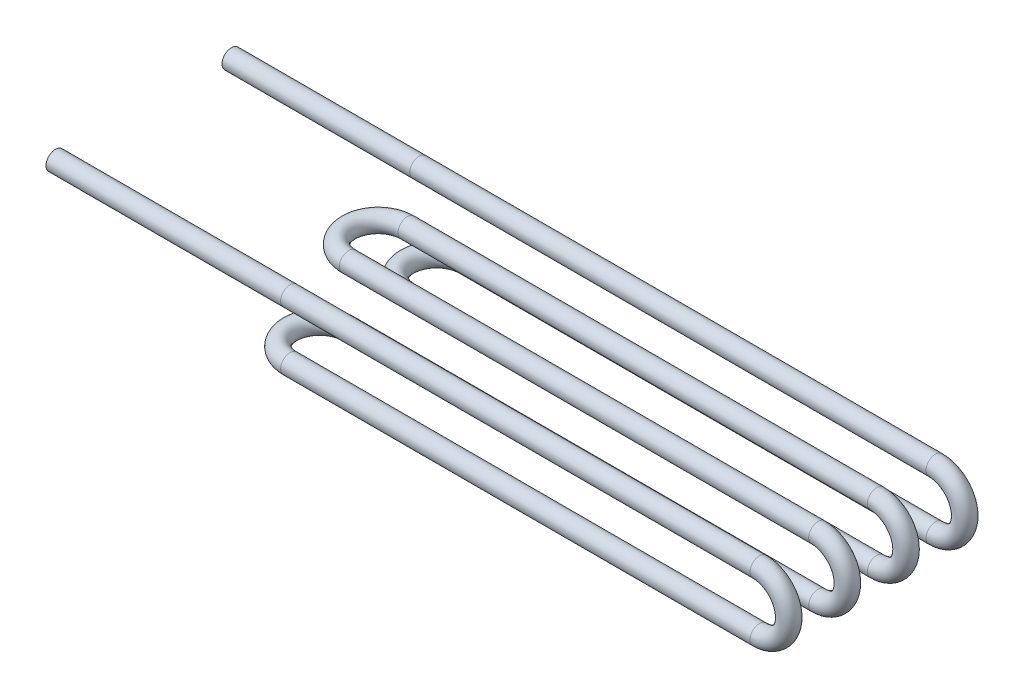
from build123d import *

# Parameters (mm, degrees)
SKETCH2_R   = 4
SKETCH2_R_2 = 3


with BuildPart() as part:
    # Sweep1: sweep along a curve in space
    with BuildLine() as sweep1_path:
        Line((20, 0, 74.999233924), (-80, 0, 74.999233924))
        Line((220, 0, 74.999233924), (20, 0, 74.999233924))
        ThreePointArc((220, 0, 74.999233924), (232.5, -12.5, 74.999233924), (220, -25, 74.999233924))
        Line((20, -25, 74.999233924), (220, -25, 74.999233924))
        ThreePointArc((20, -24.834484554, 49.999781837), (7.5, -24.917242277, 62.49950788), (20, -25, 74.999233924))
        Line((220, -24.834484554, 49.999781837), (20, -24.834484554, 49.999781837))
        ThreePointArc((220, 0.165515444, 49.999452087), (232.5, -12.334484555, 49.999616962), (220, -24.834484554, 49.999781837))
        Line((20, 0.165515444, 49.999452087), (220, 0.165515444, 49.999452087))
        ThreePointArc((20, 0.165515444, 49.999452087), (7.5, 0.165515444, 37.499452087), (20, 0.165515444, 24.999452087))
        Line((220, 0.165515444, 24.999452087), (20, 0.165515444, 24.999452087))
        ThreePointArc((220, 0.165515444, 24.999452087), (232.5, -12.334484556, 24.999452087), (220, -24.834484556, 24.999452087))
        Line((20, -24.834484556, 24.999452087), (220, -24.834484556, 24.999452087))
        ThreePointArc((20, -25, 0), (7.5, -24.917242278, 12.499726043), (20, -24.834484556, 24.999452087))
        Line((220, -25, 0), (20, -25, 0))
        ThreePointArc((220, 0, 0), (232.5, -12.5, 0), (220, -25, 0))
        Line((0, 0, 0), (220, 0, 0))
        Line((0, 0, 0), (-80, 0, 0))
    # Sketch2 → Sweep1 (sweep)
    with BuildSketch(Plane(origin=(-80, 0, 0), x_dir=(0, 0, -1), z_dir=(1, 0, 0))):
        Circle(SKETCH2_R)
        Circle(SKETCH2_R_2, mode=Mode.SUBTRACT)
    sweep(path=sweep1_path.line)


solid = part.part
